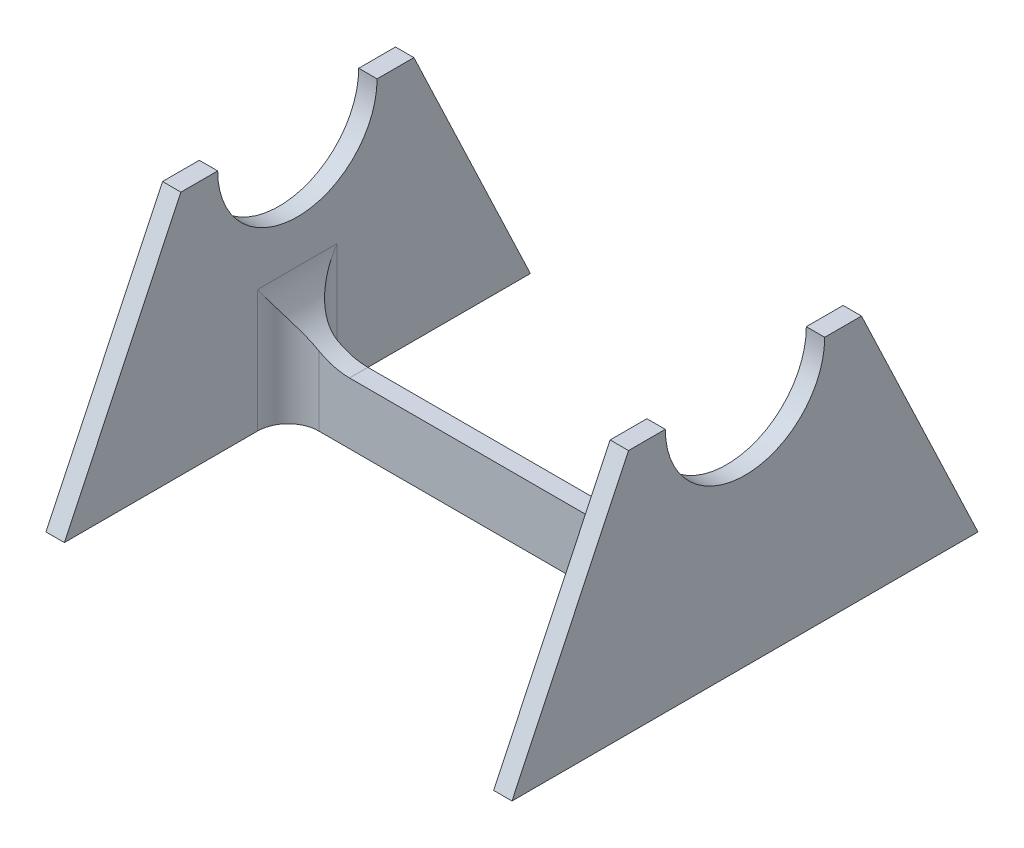
from build123d import *

# Parameters (mm, degrees)
ESQUISSE1_W             = 70
ESQUISSE1_H             = 40
BOSS_EXTRU_1_DEPTH      = 3
BOSS_EXTRU_2_DEPTH      = 3
ESQUISSE3_W             = 70
ESQUISSE3_H             = 30
ENL_V_MAT_EXTRU_1_DEPTH = 3
CONG_1_R                = 10
CONG_2_R                = 5


with BuildPart() as part:
    # Esquisse1 → Boss.-Extru.1 (new body)
    with BuildSketch(Plane.XY):
        Rectangle(ESQUISSE1_W, ESQUISSE1_H)
    extrude(amount=BOSS_EXTRU_1_DEPTH)

    # Esquisse2 → Boss.-Extru.2 (add)
    with BuildSketch(Plane(origin=(35, 0, 0), x_dir=(0, 0, -1), z_dir=(1, 0, 0))):
        with BuildLine():
            Line((-14.5, 20), (-20.5, 20))
            Line((-20.5, 20), (-39.5, -20))
            Line((-39.5, -20), (-36.086461528, -20))
            Line((-36.086461528, -20), (-7.955603951, -20))
            Line((-7.955603951, -20), (4.955603951, -20))
            Line((4.955603951, -20), (33.086461528, -20))
            Line((33.086461528, -20), (36.5, -20))
            Line((36.5, -20), (17.5, 20))
            Line((17.5, 20), (11.5, 20))
            ThreePointArc((11.5, 20), (7.692388155, 10.807611845), (-1.5, 7))
            ThreePointArc((-1.5, 7), (-10.692388155, 10.807611845), (-14.5, 20))
        make_face()
    boss_extru_2 = extrude(amount=BOSS_EXTRU_2_DEPTH)

    # Symétrie1: Boss.-Extru.2 across plane
    add(boss_extru_2.mirror(Plane(origin=(0, 0, 0), x_dir=(0, 0, 1), z_dir=(1, 0, 0))))

    # Esquisse3 → Enlèv. mat.-Extru.1 (cut)
    with BuildSketch(Plane.XY.offset(3)):
        with Locations((0, 5)):
            Rectangle(ESQUISSE3_W, ESQUISSE3_H)
    extrude(amount=-ENL_V_MAT_EXTRU_1_DEPTH, mode=Mode.SUBTRACT)

    # Congé1
    cong_1_edges = [part.edges().sort_by_distance(p)[0] for p in [
        (-35, -10, 1.5),
        (35, -10, 1.5),
    ]]
    fillet(cong_1_edges, radius=CONG_1_R)

    # Congé2
    cong_2_edges = [part.edges().sort_by_distance(p)[0] for p in [
        (35, -5, 0),
        (-35, -5, 0),
        (-35, -5, 3),
        (35, -5, 3),
    ]]
    fillet(cong_2_edges, radius=CONG_2_R)


solid = part.part
